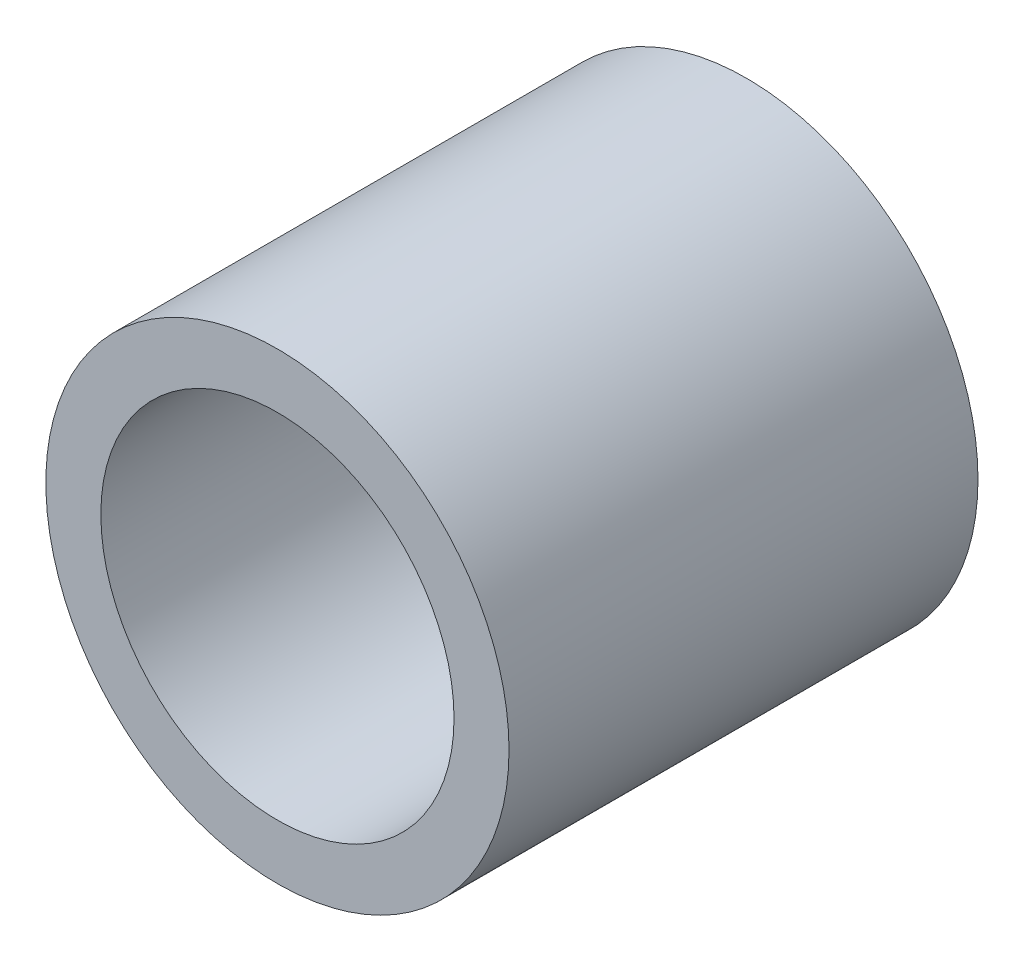
from build123d import *

# Parameters (mm, degrees)
SKETCH1_R           = 4
SKETCH1_R_2         = 3.05
BOSS_EXTRUDE1_DEPTH = 8.1


with BuildPart() as part:
    # Sketch1 → Boss-Extrude1 (new body)
    with BuildSketch(Plane.XY):
        with Locations((0, -0.812375766)):
            Circle(SKETCH1_R)
        with Locations((0, -0.812375766)):
            Circle(SKETCH1_R_2, mode=Mode.SUBTRACT)
    extrude(amount=BOSS_EXTRUDE1_DEPTH)


solid = part.part
